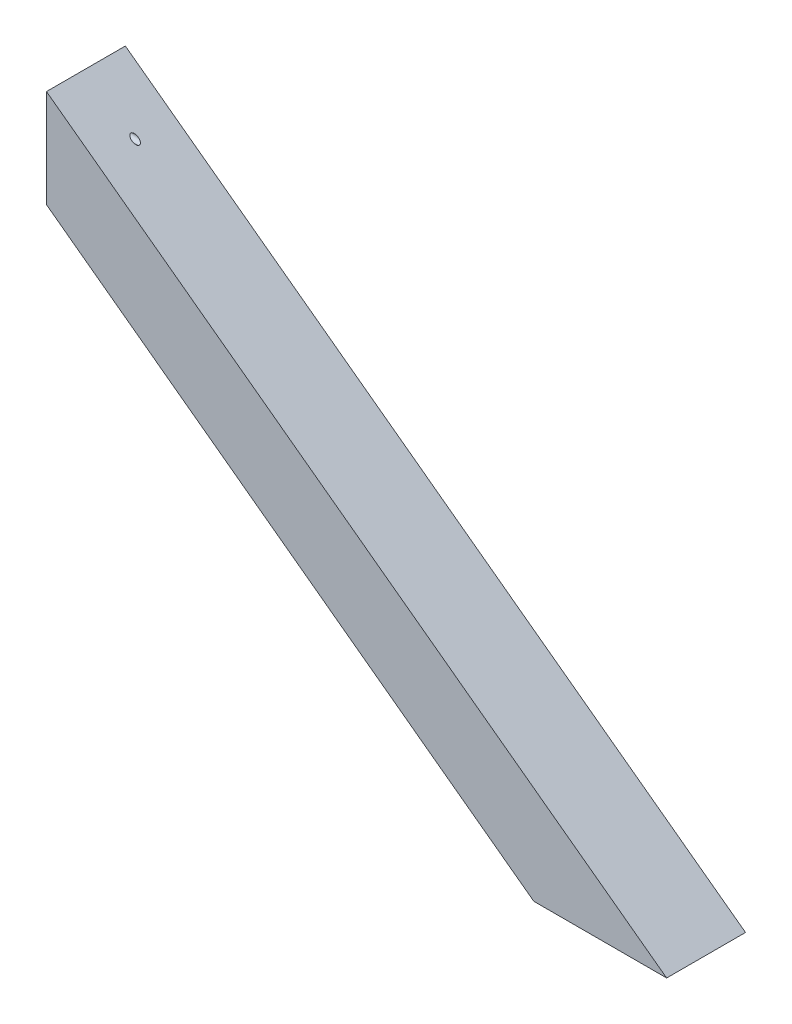
from build123d import *

# Parameters (mm, degrees)
BOSS_EXTRU_1_DEPTH      = 44
ENL_V_MAT_EXTRU_1_REACH = 348
ESQUISSE2_R             = 1.75


with BuildPart() as part:
    # Esquisse1 → Boss.-Extru.1 (new body)
    with BuildSketch(Plane.XY):
        Polygon((-97.60917289, 115.219928183), (-97.60917289, 60.537847258), (174.28529528, -140.091646173), (248.39082711, -140.091646173), align=None)
    extrude(amount=BOSS_EXTRU_1_DEPTH)

    # Enlèv. mat.-Extru.1: up to this face of the body (flat: up to its plane)
    enl_v_mat_extru_1_end = Plane(part.part.faces().sort_by_distance((75.39082711, -12.435858995, 22))[0])
    # Esquisse2 → Enlèv. mat.-Extru.1 (cut, up to the picked face)
    with BuildSketch(Plane.ZY.offset(97.60917289), mode=Mode.PRIVATE) as enl_v_mat_extru_1_sk1:
        with Locations((22, 94.969928183)):
            Circle(ESQUISSE2_R)
    enl_v_mat_extru_1_tool1 = split(extrude(enl_v_mat_extru_1_sk1.sketch, amount=-ENL_V_MAT_EXTRU_1_REACH, mode=Mode.PRIVATE), bisect_by=enl_v_mat_extru_1_end, keep=Keep.BOTH, mode=Mode.PRIVATE)
    add(enl_v_mat_extru_1_tool1.solids().sort_by_distance((-97.609173, 94.969928, 22))[0], mode=Mode.SUBTRACT)


solid = part.part
